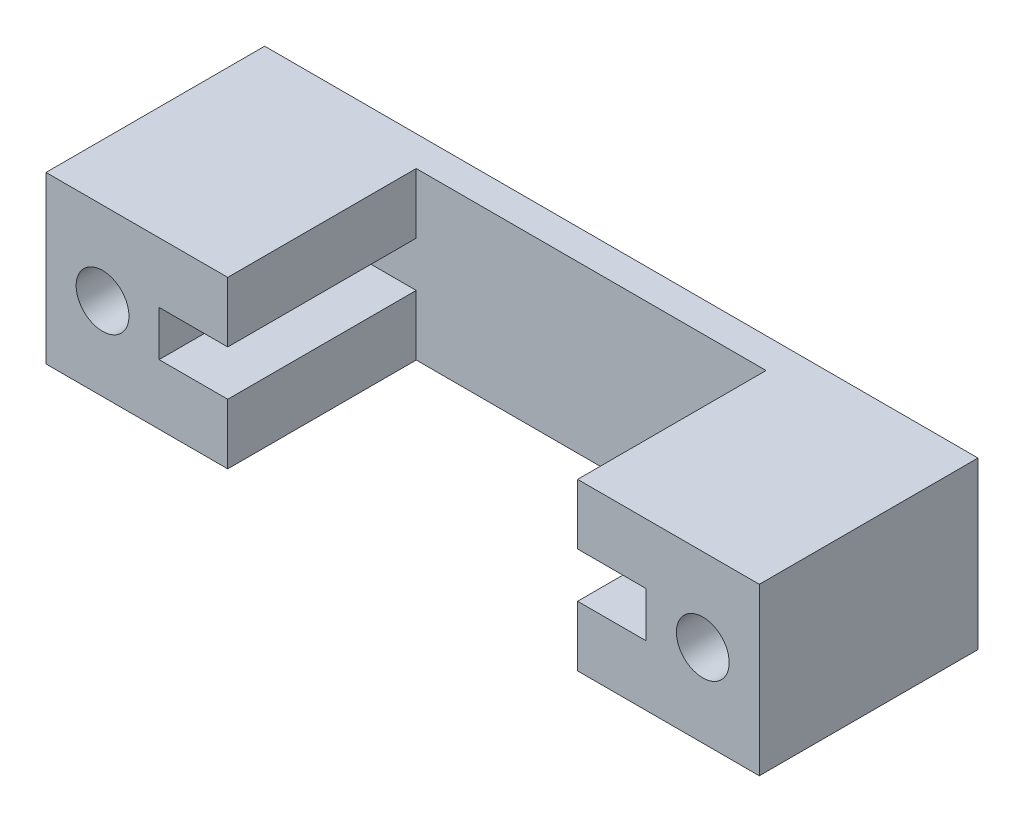
from build123d import *

# Parameters (mm, degrees)
SKETCH1_R           = 1.75
BOSS_EXTRUDE1_DEPTH = 2
BOSS_EXTRUDE2_START = 2
SKETCH1_3_R         = 1.75
BOSS_EXTRUDE2_DEPTH = 12.5


with BuildPart() as part:
    # Sketch1 → Boss-Extrude1 (new body)
    with BuildSketch(Plane.XY):
        Polygon((-23.65, 5.5), (-23.65, -5.5), (-11.6, -5.5), (-11.6, -1.5), (-16.15, -1.5), (-16.15, 1.5), (-11.6, 1.5), (-11.6, 5.5), align=None)
        with Locations((-19.9, 0)):
            Circle(SKETCH1_R, mode=Mode.SUBTRACT)
        Polygon((-11.6, 1.5), (-11.6, 5.5), (11.6, 5.5), (11.6, 1.5), (16.15, 1.5), (16.15, -1.5), (11.6, -1.5), (11.6, -5.5), (-11.6, -5.5), (-11.6, -1.5), (-16.15, -1.5), (-16.15, 1.5), align=None)
        Polygon((23.65, -5.5), (11.6, -5.5), (11.6, -1.5), (16.15, -1.5), (16.15, 1.5), (11.6, 1.5), (11.6, 5.5), (23.65, 5.5), align=None)
        with Locations((19.9, 0)):
            Circle(SKETCH1_R, mode=Mode.SUBTRACT)
    extrude(amount=BOSS_EXTRUDE1_DEPTH)

    # Sketch1_3 → Boss-Extrude2 (add)
    with BuildSketch(Plane.XY.offset(BOSS_EXTRUDE2_START)):
        Polygon((-23.65, 5.5), (-23.65, -5.5), (-11.6, -5.5), (-11.6, -1.5), (-16.15, -1.5), (-16.15, 1.5), (-11.6, 1.5), (-11.6, 5.5), align=None)
        with Locations((-19.9, 0)):
            Circle(SKETCH1_3_R, mode=Mode.SUBTRACT)
        Polygon((23.65, -5.5), (11.6, -5.5), (11.6, -1.5), (16.15, -1.5), (16.15, 1.5), (11.6, 1.5), (11.6, 5.5), (23.65, 5.5), align=None)
        with Locations((19.9, 0)):
            Circle(SKETCH1_3_R, mode=Mode.SUBTRACT)
    extrude(amount=BOSS_EXTRUDE2_DEPTH)


solid = part.part
